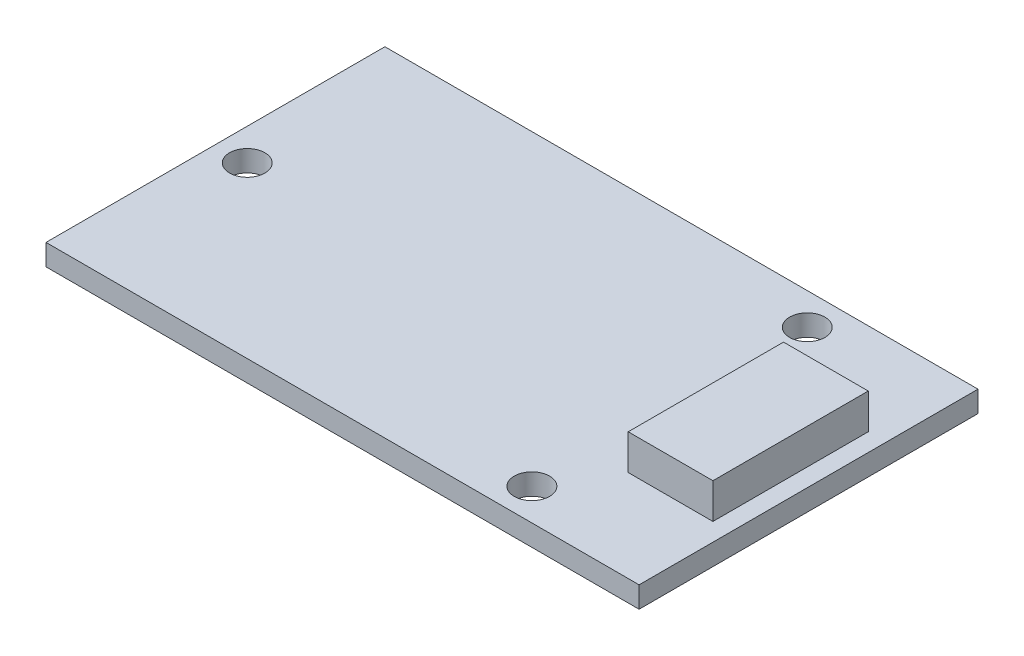
from build123d import *

# Parameters (mm, degrees)
SKETCH2_W           = 42
SKETCH2_H           = 24
SKETCH2_R           = 1.25
BOSS_EXTRUDE1_DEPTH = 1.5
SKETCH2_9_W         = 6
SKETCH2_9_H         = 11
BOSS_EXTRUDE2_DEPTH = 4


with BuildPart() as part:
    # Sketch2 → Boss-Extrude1 (new body)
    with BuildSketch(Plane(origin=(0, 0, 0), x_dir=(1, 0, 0), z_dir=(0, 1, 0))):
        with Locations((21, -12)):
            Rectangle(SKETCH2_W, SKETCH2_H)
        with Locations((32.16, -21.75)):
            Circle(SKETCH2_R, mode=Mode.SUBTRACT)
        with Locations((2.25, -12)):
            Circle(SKETCH2_R, mode=Mode.SUBTRACT)
        with Locations((32.16, -2.25)):
            Circle(SKETCH2_R, mode=Mode.SUBTRACT)
    extrude(amount=BOSS_EXTRUDE1_DEPTH)

    # Sketch2_9 → Boss-Extrude2 (add)
    with BuildSketch(Plane(origin=(0, 0, 0), x_dir=(1, 0, 0), z_dir=(0, 1, 0))):
        with Locations((37.7285084, -12)):
            Rectangle(SKETCH2_9_W, SKETCH2_9_H)
    extrude(amount=BOSS_EXTRUDE2_DEPTH)


solid = part.part
